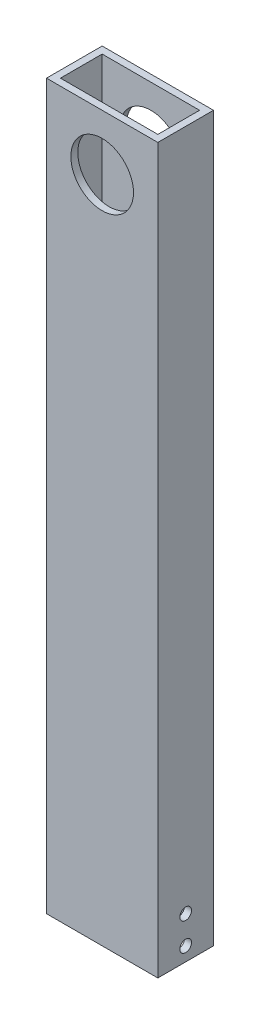
from build123d import *

# Parameters (mm, degrees)
SKETCH1_W           = 50.8
SKETCH1_H           = 25.4
SKETCH1_W_2         = 44.45
SKETCH1_H_2         = 19.05
BOSS_EXTRUDE2_DEPTH = 330.2
SKETCH2_R           = 14.2875
CUT_EXTRUDE1_DEPTH  = 25.4
SKETCH3_R           = 2.667
CUT_EXTRUDE2_DEPTH  = 3.175


with BuildPart() as part:
    # Sketch1 → Boss-Extrude2 (new body)
    with BuildSketch(Plane(origin=(0, 0, 0), x_dir=(1, 0, 0), z_dir=(0, 1, 0))):
        with Locations((25.4, 12.7)):
            Rectangle(SKETCH1_W, SKETCH1_H)
        with Locations((25.4, 12.7)):
            Rectangle(SKETCH1_W_2, SKETCH1_H_2, mode=Mode.SUBTRACT)
    extrude(amount=BOSS_EXTRUDE2_DEPTH)

    # Sketch2 → Cut-Extrude1 (cut)
    with BuildSketch(Plane.XY):
        with Locations((25.4, 304.8)):
            Circle(SKETCH2_R)
    extrude(amount=-CUT_EXTRUDE1_DEPTH, mode=Mode.SUBTRACT)

    # Sketch3 → Cut-Extrude2 (cut)
    with BuildSketch(Plane(origin=(50.8, 0, 0), x_dir=(0, 0, -1), z_dir=(1, 0, 0))):
        with Locations((12.7, 19.05)):
            Circle(SKETCH3_R)
        with Locations((12.7, 6.35)):
            Circle(SKETCH3_R)
    extrude(amount=-CUT_EXTRUDE2_DEPTH, mode=Mode.SUBTRACT)


solid = part.part
